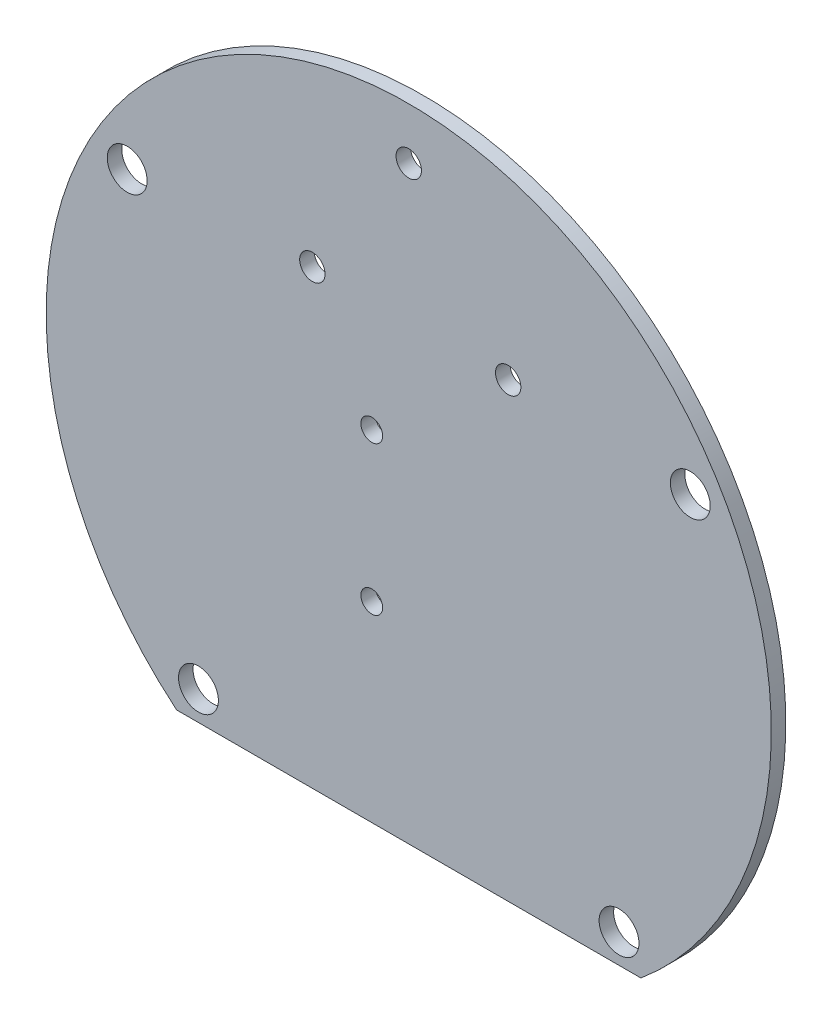
from build123d import *

# Parameters (mm, degrees)
ESBO_O1_R                  = 50
RESSALTO_EXTRUS_O1_DEPTH   = 2
ESBO_O2_R                  = 2.75
CORTE_EXTRUS_O1_DEPTH      = 2
CORTE_EXTRUS_O2_DEPTH      = 1
CORTE_EXTRUS_O2_DEPTH_BACK = 10
ESBO_O5_R                  = 1.5
ESBO_O5_R_2                = 1.75
CORTE_EXTRUS_O3_DEPTH      = 10


with BuildPart() as part:
    # Esboço1 → Ressalto-extrusão1 (new body)
    with BuildSketch(Plane.XY):
        Circle(ESBO_O1_R)
    extrude(amount=RESSALTO_EXTRUS_O1_DEPTH)

    # Esboço2 → Corte-extrusão1 (cut)
    with BuildSketch(Plane.XY.offset(2)):
        with Locations((-29, -34.409301068)):
            Circle(ESBO_O2_R)
        with Locations((29, -34.409301068)):
            Circle(ESBO_O2_R)
        with Locations((-38.824197531, 22.752619324)):
            Circle(ESBO_O2_R)
        with Locations((38.824197531, 22.752619324)):
            Circle(ESBO_O2_R)
    extrude(amount=-CORTE_EXTRUS_O1_DEPTH, mode=Mode.SUBTRACT)

    # Esboço4 → Corte-extrusão2 (cut, two sides)
    with BuildSketch(Plane.XY.offset(2)) as corte_extrus_o2_sk:
        Polygon((-40.723859979, -38.409301068), (44.57073926, -38.409301068), (1.923439641, -68.002213614), align=None)
    extrude(amount=CORTE_EXTRUS_O2_DEPTH, mode=Mode.SUBTRACT)
    extrude(corte_extrus_o2_sk.sketch, amount=-CORTE_EXTRUS_O2_DEPTH_BACK, mode=Mode.SUBTRACT)

    # Esboço5 → Corte-extrusão3 (cut)
    with BuildSketch(Plane(origin=(0, 0, 0), x_dir=(-1, 0, 0), z_dir=(0, 0, -1))):
        with Locations((5.1, 8.5)):
            Circle(ESBO_O5_R)
        with Locations((5.1, -12)):
            Circle(ESBO_O5_R)
        with Locations((-13.71, 23.86)):
            Circle(ESBO_O5_R_2)
        with Locations((13.29, 23.86)):
            Circle(ESBO_O5_R_2)
        with Locations((0, 42.87)):
            Circle(ESBO_O5_R_2)
    extrude(amount=-CORTE_EXTRUS_O3_DEPTH, mode=Mode.SUBTRACT)


solid = part.part
